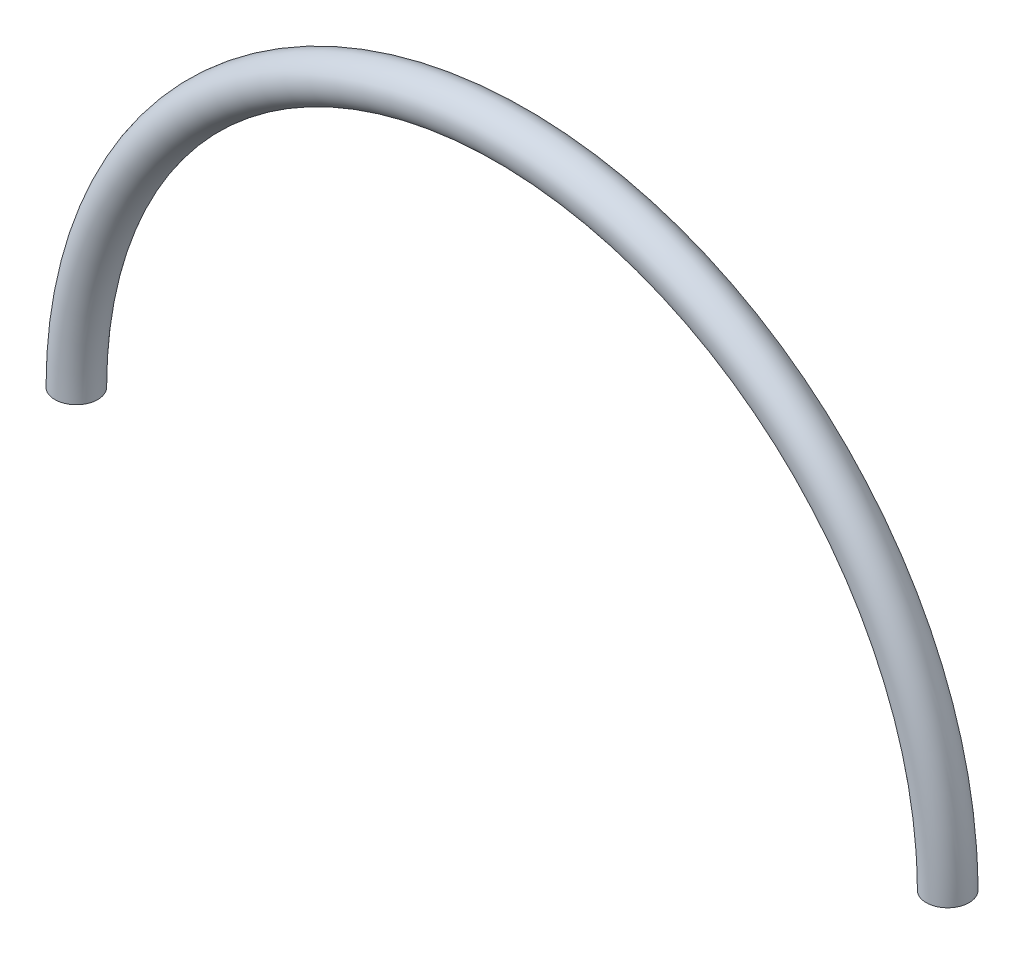
from build123d import *

# Parameters (mm, degrees)
SKETCH3_R = 3.175


with BuildPart() as part:
    # Sweep1: sweep along a path in Sketch2
    with BuildLine(Plane.XY) as sweep1_path:
        ThreePointArc((0, 0), (64.5, 64.5), (129, 0))
    # Sketch3 → Sweep1 (sweep)
    with BuildSketch(Plane(origin=(0, 0, 0), x_dir=(1, 0, 0), z_dir=(0, 1, 0))):
        Circle(SKETCH3_R)
    sweep(path=sweep1_path.line)


solid = part.part
